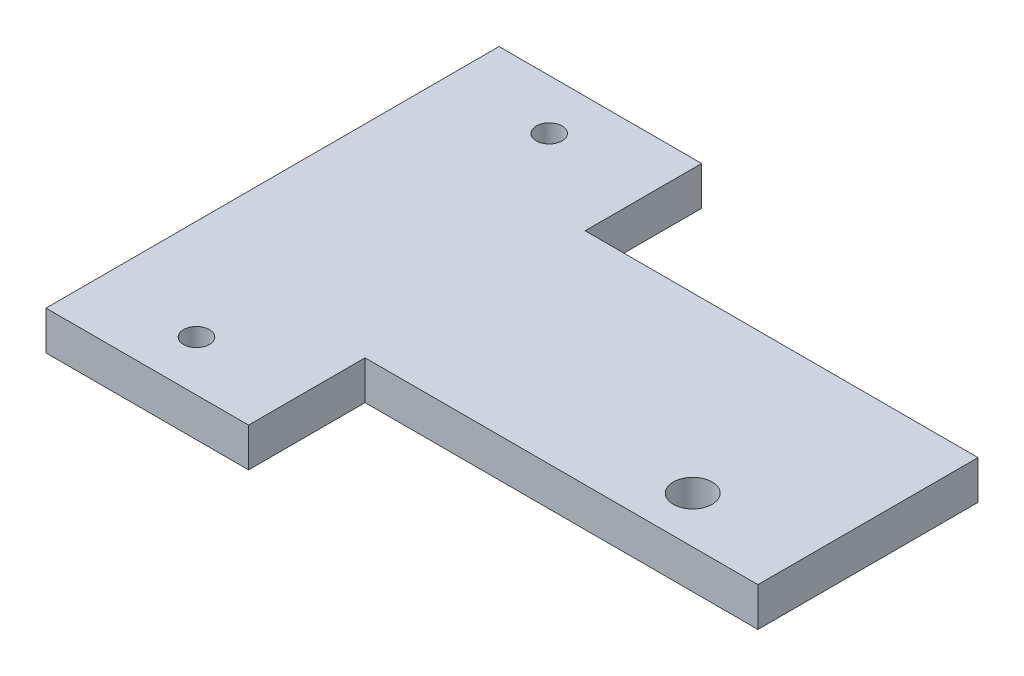
from build123d import *

# Parameters (mm, degrees)
SKETCH1_W           = 46
SKETCH1_H           = 17
BOSS_EXTRUDE1_DEPTH = 3
SKETCH2_W           = 15.65
SKETCH2_H           = 3
BOSS_EXTRUDE2_DEPTH = 9
SKETCH3_R           = 1
CUT_EXTRUDE1_DEPTH  = 10
SKETCH4_R           = 1.5
CUT_EXTRUDE2_DEPTH  = 10


with BuildPart() as part:
    # Sketch1 → Boss-Extrude1 (new body)
    with BuildSketch(Plane(origin=(0, 0, 0), x_dir=(1, 0, 0), z_dir=(0, 1, 0))):
        Rectangle(SKETCH1_W, SKETCH1_H)
    extrude(amount=BOSS_EXTRUDE1_DEPTH)

    # Sketch2 → Boss-Extrude2 (add)
    with BuildSketch(Plane(origin=(0, 0, -8.5), x_dir=(-1, 0, 0), z_dir=(0, 0, -1))):
        with Locations((15.175, 1.5)):
            Rectangle(SKETCH2_W, SKETCH2_H)
    boss_extrude2 = extrude(amount=BOSS_EXTRUDE2_DEPTH)

    # Mirror1: Boss-Extrude2 across plane
    add(boss_extrude2.mirror(Plane.XY))

    # Sketch3 → Cut-Extrude1 (cut)
    with BuildSketch(Plane(origin=(0, 3, 0), x_dir=(1, 0, 0), z_dir=(0, 1, 0))):
        with Locations((-15.25, 13.625)):
            Circle(SKETCH3_R)
        with Locations((-15.25, -13.625)):
            Circle(SKETCH3_R)
    extrude(amount=-CUT_EXTRUDE1_DEPTH, mode=Mode.SUBTRACT)

    # Sketch4 → Cut-Extrude2 (cut)
    with BuildSketch(Plane(origin=(0, 3, 0), x_dir=(1, 0, 0), z_dir=(0, 1, 0))):
        with Locations((14.36, -4.9)):
            Circle(SKETCH4_R)
    extrude(amount=-CUT_EXTRUDE2_DEPTH, mode=Mode.SUBTRACT)


solid = part.part
